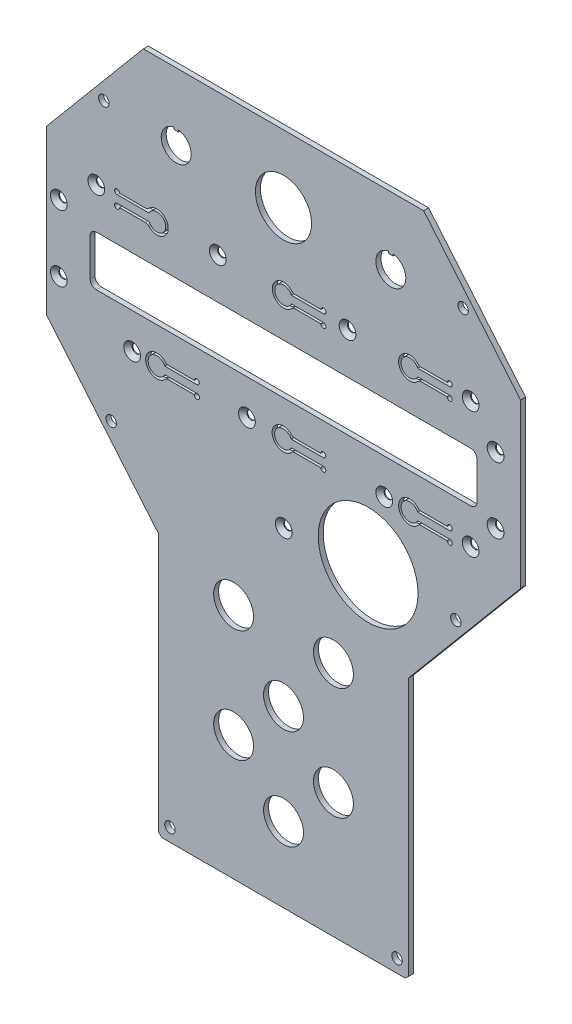
from build123d import *

# Parameters (mm, degrees)
RESSALTO_EXTRUS_O1_DEPTH                      = 2
CORTE_EXTRUS_O1_REACH                         = 4
ESBO_O2_R                                     = 2.1
CORTE_EXTRUS_O2_REACH                         = 4
CORTE_EXTRUS_O3_REACH                         = 4
ESBO_O4_R                                     = 20
CORTE_EXTRUS_O4_REACH                         = 4
ESBO_O5_R                                     = 8
ESBO_O5_R_2                                   = 11.25
ESCAREADO_PARA_PARAFUSO_ALLEN_SEXTAV_2_COUNT  = 2
ESCAREADO_PARA_PARAFUSO_ALLEN_SEXTAV_2_PITCH  = 26.5
ESCAREADO_PARA_PARAFUSO_ALLEN_SEXTAV_3_COUNT  = 2
ESCAREADO_PARA_PARAFUSO_ALLEN_SEXTAV_3_PITCH  = 47.918783057
ESCAREADO_PARA_PARAFUSO_ALLEN_SEXTAV_4_COUNT  = 2
ESCAREADO_PARA_PARAFUSO_ALLEN_SEXTAV_4_PITCH  = 84.354894452
ESCAREADO_PARA_PARAFUSO_ALLEN_SEXTAV_5_COUNT  = 2
ESCAREADO_PARA_PARAFUSO_ALLEN_SEXTAV_5_PITCH  = 135.769067452
ESCAREADO_PARA_PARAFUSO_ALLEN_SEXTAV_6_COUNT  = 2
ESCAREADO_PARA_PARAFUSO_ALLEN_SEXTAV_6_PITCH  = 176.995056428
ESCAREADO_PARA_PARAFUSO_ALLEN_SEXTAV_7_COUNT  = 2
ESCAREADO_PARA_PARAFUSO_ALLEN_SEXTAV_7_PITCH  = 175
ESCAREADO_PARA_PARAFUSO_ALLEN_SEXTAV_8_COUNT  = 2
ESCAREADO_PARA_PARAFUSO_ALLEN_SEXTAV_8_PITCH  = 116.384068539
ESCAREADO_PARA_PARAFUSO_ALLEN_SEXTAV_9_COUNT  = 2
ESCAREADO_PARA_PARAFUSO_ALLEN_SEXTAV_9_PITCH  = 64.945475466
ESCAREADO_PARA_PARAFUSO_ALLEN_SEXTAV_10_COUNT = 2
ESCAREADO_PARA_PARAFUSO_ALLEN_SEXTAV_10_PITCH = 113.39334618
CORTE_EXTRUS_O5_DEPTH                         = 10
FILETE1_R                                     = 2
ESCAREADO_PARA_PARAFUSO_ALLEN_SEXTAV_12_COUNT = 2
ESCAREADO_PARA_PARAFUSO_ALLEN_SEXTAV_12_PITCH = 150
ESCAREADO_PARA_PARAFUSO_ALLEN_SEXTAV_13_COUNT = 2
ESCAREADO_PARA_PARAFUSO_ALLEN_SEXTAV_13_PITCH = 158.297944738


with BuildPart() as part:
    # Esboço1 → Ressalto-extrusão1 (new body)
    with BuildSketch(Plane.XY):
        Polygon((55.321046002, 133.809611411), (-57.006999458, 133.809611411), (-95.842976728, 87.526695978), (-95.842976728, 22.140182404), (-50.842976728, -31.488729263), (-50.842976728, -135.082673958), (-49.522853837, -136.190388589), (47.836900381, -136.190388589), (49.157023272, -135.082673958), (49.157023272, -31.488729263), (94.157023272, 22.140182404), (94.157023272, 87.526695978), align=None)
    extrude(amount=RESSALTO_EXTRUS_O1_DEPTH)

    # Esboço2 → Corte-extrusão1 (cut, up to next)
    with BuildSketch(Plane.XY.offset(2), mode=Mode.PRIVATE) as corte_extrus_o1_sk1:
        with Locations((-72.814392548, 107.949888211)):
            Circle(ESBO_O2_R)
    corte_extrus_o1_tool1 = extrude(corte_extrus_o1_sk1.sketch, amount=-CORTE_EXTRUS_O1_REACH, mode=Mode.PRIVATE) & part.part
    add(corte_extrus_o1_tool1.solids().sort_by_distance((-72.814393, 107.949888, 2))[0], mode=Mode.SUBTRACT)
    # Esboço2 → Corte-extrusão1 (cut, up to next)
    with BuildSketch(Plane.XY.offset(2), mode=Mode.PRIVATE) as corte_extrus_o1_sk2:
        with Locations((-46.342976728, -130.964393909)):
            Circle(ESBO_O2_R)
    corte_extrus_o1_tool2 = extrude(corte_extrus_o1_sk2.sketch, amount=-CORTE_EXTRUS_O1_REACH, mode=Mode.PRIVATE) & part.part
    add(corte_extrus_o1_tool2.solids().sort_by_distance((-46.342977, -130.964394, 2))[0], mode=Mode.SUBTRACT)
    # Esboço2 → Corte-extrusão1 (cut, up to next)
    with BuildSketch(Plane.XY.offset(2), mode=Mode.PRIVATE) as corte_extrus_o1_sk3:
        with Locations((44.657023272, -130.964393909)):
            Circle(ESBO_O2_R)
    corte_extrus_o1_tool3 = extrude(corte_extrus_o1_sk3.sketch, amount=-CORTE_EXTRUS_O1_REACH, mode=Mode.PRIVATE) & part.part
    add(corte_extrus_o1_tool3.solids().sort_by_distance((44.657023, -130.964394, 2))[0], mode=Mode.SUBTRACT)
    # Esboço2 → Corte-extrusão1 (cut, up to next)
    with BuildSketch(Plane.XY.offset(2), mode=Mode.PRIVATE) as corte_extrus_o1_sk4:
        with Locations((71.128439092, 107.949888211)):
            Circle(ESBO_O2_R)
    corte_extrus_o1_tool4 = extrude(corte_extrus_o1_sk4.sketch, amount=-CORTE_EXTRUS_O1_REACH, mode=Mode.PRIVATE) & part.part
    add(corte_extrus_o1_tool4.solids().sort_by_distance((71.128439, 107.949888, 2))[0], mode=Mode.SUBTRACT)
    # Esboço2 → Corte-extrusão1 (cut, up to next)
    with BuildSketch(Plane.XY.offset(2), mode=Mode.PRIVATE) as corte_extrus_o1_sk5:
        with Locations((-69.895776734, -1.781729186)):
            Circle(ESBO_O2_R)
    corte_extrus_o1_tool5 = extrude(corte_extrus_o1_sk5.sketch, amount=-CORTE_EXTRUS_O1_REACH, mode=Mode.PRIVATE) & part.part
    add(corte_extrus_o1_tool5.solids().sort_by_distance((-69.895777, -1.781729, 2))[0], mode=Mode.SUBTRACT)
    # Esboço2 → Corte-extrusão1 (cut, up to next)
    with BuildSketch(Plane.XY.offset(2), mode=Mode.PRIVATE) as corte_extrus_o1_sk6:
        with Locations((68.209823278, -1.781729186)):
            Circle(ESBO_O2_R)
    corte_extrus_o1_tool6 = extrude(corte_extrus_o1_sk6.sketch, amount=-CORTE_EXTRUS_O1_REACH, mode=Mode.PRIVATE) & part.part
    add(corte_extrus_o1_tool6.solids().sort_by_distance((68.209823, -1.781729, 2))[0], mode=Mode.SUBTRACT)

    # Esboço3 → Corte-extrusão2 (cut, up to next)
    with BuildSketch(Plane.XY.offset(2), mode=Mode.PRIVATE) as corte_extrus_o2_sk1:
        with BuildLine():
            Line((-75.842976728, 40.809611411), (74.157023272, 40.809611411))
            ThreePointArc((74.157023272, 40.809611411), (75.924790225, 41.541844458), (76.657023272, 43.309611411))
            Line((76.657023272, 43.309611411), (76.657023272, 58.309611411))
            ThreePointArc((76.657023272, 58.309611411), (75.924790225, 60.077378364), (74.157023272, 60.809611411))
            Line((74.157023272, 60.809611411), (-75.842976728, 60.809611411))
            ThreePointArc((-75.842976728, 60.809611411), (-77.610743681, 60.077378364), (-78.342976728, 58.309611411))
            Line((-78.342976728, 58.309611411), (-78.342976728, 43.309611411))
            ThreePointArc((-78.342976728, 43.309611411), (-77.610743681, 41.541844458), (-75.842976728, 40.809611411))
        make_face()
    corte_extrus_o2_tool1 = extrude(corte_extrus_o2_sk1.sketch, amount=-CORTE_EXTRUS_O2_REACH, mode=Mode.PRIVATE) & part.part
    add(corte_extrus_o2_tool1.solids().sort_by_distance((-0.842977, 50.809611, 2))[0], mode=Mode.SUBTRACT)

    # Esboço4 → Corte-extrusão3 (cut, up to next)
    with BuildSketch(Plane.XY.offset(2), mode=Mode.PRIVATE) as corte_extrus_o3_sk1:
        with Locations((33.056325833, -0.190388589)):
            Circle(ESBO_O4_R)
    corte_extrus_o3_tool1 = extrude(corte_extrus_o3_sk1.sketch, amount=-CORTE_EXTRUS_O3_REACH, mode=Mode.PRIVATE) & part.part
    add(corte_extrus_o3_tool1.solids().sort_by_distance((33.056326, -0.190389, 2))[0], mode=Mode.SUBTRACT)

    # Esboço5 → Corte-extrusão4 (cut, up to next)
    with BuildSketch(Plane.XY.offset(2), mode=Mode.PRIVATE) as corte_extrus_o4_sk1:
        with Locations((-20.842976728, -86.190388589)):
            Circle(ESBO_O5_R)
    corte_extrus_o4_tool1 = extrude(corte_extrus_o4_sk1.sketch, amount=-CORTE_EXTRUS_O4_REACH, mode=Mode.PRIVATE) & part.part
    add(corte_extrus_o4_tool1.solids().sort_by_distance((-20.842977, -86.190389, 2))[0], mode=Mode.SUBTRACT)
    # Esboço5 → Corte-extrusão4 (cut, up to next)
    with BuildSketch(Plane.XY.offset(2), mode=Mode.PRIVATE) as corte_extrus_o4_sk2:
        with Locations((19.157023272, -86.190388589)):
            Circle(ESBO_O5_R)
    corte_extrus_o4_tool2 = extrude(corte_extrus_o4_sk2.sketch, amount=-CORTE_EXTRUS_O4_REACH, mode=Mode.PRIVATE) & part.part
    add(corte_extrus_o4_tool2.solids().sort_by_distance((19.157023, -86.190389, 2))[0], mode=Mode.SUBTRACT)
    # Esboço5 → Corte-extrusão4 (cut, up to next)
    with BuildSketch(Plane.XY.offset(2), mode=Mode.PRIVATE) as corte_extrus_o4_sk3:
        with Locations((-0.842976728, -106.190388589)):
            Circle(ESBO_O5_R)
    corte_extrus_o4_tool3 = extrude(corte_extrus_o4_sk3.sketch, amount=-CORTE_EXTRUS_O4_REACH, mode=Mode.PRIVATE) & part.part
    add(corte_extrus_o4_tool3.solids().sort_by_distance((-0.842977, -106.190389, 2))[0], mode=Mode.SUBTRACT)
    # Esboço5 → Corte-extrusão4 (cut, up to next)
    with BuildSketch(Plane.XY.offset(2), mode=Mode.PRIVATE) as corte_extrus_o4_sk4:
        with Locations((-0.842976728, -66.190388589)):
            Circle(ESBO_O5_R)
    corte_extrus_o4_tool4 = extrude(corte_extrus_o4_sk4.sketch, amount=-CORTE_EXTRUS_O4_REACH, mode=Mode.PRIVATE) & part.part
    add(corte_extrus_o4_tool4.solids().sort_by_distance((-0.842977, -66.190389, 2))[0], mode=Mode.SUBTRACT)
    # Esboço5 → Corte-extrusão4 (cut, up to next)
    with BuildSketch(Plane.XY.offset(2), mode=Mode.PRIVATE) as corte_extrus_o4_sk5:
        with Locations((-20.842976728, -41.190388589)):
            Circle(ESBO_O5_R)
    corte_extrus_o4_tool5 = extrude(corte_extrus_o4_sk5.sketch, amount=-CORTE_EXTRUS_O4_REACH, mode=Mode.PRIVATE) & part.part
    add(corte_extrus_o4_tool5.solids().sort_by_distance((-20.842977, -41.190389, 2))[0], mode=Mode.SUBTRACT)
    # Esboço5 → Corte-extrusão4 (cut, up to next)
    with BuildSketch(Plane.XY.offset(2), mode=Mode.PRIVATE) as corte_extrus_o4_sk6:
        with Locations((19.157023272, -41.190388589)):
            Circle(ESBO_O5_R)
    corte_extrus_o4_tool6 = extrude(corte_extrus_o4_sk6.sketch, amount=-CORTE_EXTRUS_O4_REACH, mode=Mode.PRIVATE) & part.part
    add(corte_extrus_o4_tool6.solids().sort_by_distance((19.157023, -41.190389, 2))[0], mode=Mode.SUBTRACT)
    # Esboço5 → Corte-extrusão4 (cut, up to next)
    with BuildSketch(Plane.XY.offset(2), mode=Mode.PRIVATE) as corte_extrus_o4_sk7:
        with Locations((-0.842976728, 106.809611411)):
            Circle(ESBO_O5_R_2)
    corte_extrus_o4_tool7 = extrude(corte_extrus_o4_sk7.sketch, amount=-CORTE_EXTRUS_O4_REACH, mode=Mode.PRIVATE) & part.part
    add(corte_extrus_o4_tool7.solids().sort_by_distance((-0.842977, 106.809611, 2))[0], mode=Mode.SUBTRACT)
    # Esboço5 → Corte-extrusão4 (cut, up to next)
    with BuildSketch(Plane.XY.offset(2), mode=Mode.PRIVATE) as corte_extrus_o4_sk8:
        with BuildLine():
            Line((-44.742976728, 112.741727391), (-44.742976728, 111.941727391))
            Line((-44.742976728, 111.941727391), (-42.942976728, 111.941727391))
            Line((-42.942976728, 111.941727391), (-42.942976728, 112.741727391))
            ThreePointArc((-42.942976728, 112.741727391), (-43.842976728, 100.809611411), (-44.742976728, 112.741727391))
        make_face()
    corte_extrus_o4_tool8 = extrude(corte_extrus_o4_sk8.sketch, amount=-CORTE_EXTRUS_O4_REACH, mode=Mode.PRIVATE) & part.part
    add(corte_extrus_o4_tool8.solids().sort_by_distance((-43.842977, 106.733858, 2))[0], mode=Mode.SUBTRACT)
    # Esboço5 → Corte-extrusão4 (cut, up to next)
    with BuildSketch(Plane.XY.offset(2), mode=Mode.PRIVATE) as corte_extrus_o4_sk9:
        with BuildLine():
            Line((41.257023272, 112.741727391), (41.257023272, 111.941727391))
            Line((41.257023272, 111.941727391), (43.057023272, 111.941727391))
            Line((43.057023272, 111.941727391), (43.057023272, 112.741727391))
            ThreePointArc((43.057023272, 112.741727391), (42.157023272, 100.809611411), (41.257023272, 112.741727391))
        make_face()
    corte_extrus_o4_tool9 = extrude(corte_extrus_o4_sk9.sketch, amount=-CORTE_EXTRUS_O4_REACH, mode=Mode.PRIVATE) & part.part
    add(corte_extrus_o4_tool9.solids().sort_by_distance((42.157023, 106.733858, 2))[0], mode=Mode.SUBTRACT)

    # Esboço11 → Escareado para parafuso Allen sextavado (revolve, cut)
    with BuildSketch(Plane(origin=(-90.868976728, 64.471011411, 2), x_dir=(0, -1, 0), z_dir=(1, 0, 0))):
        Polygon((0, 0), (0, 2), (1.7, 2), (1.7, 1.66), (3.36, 0), align=None)
    escareado_para_parafuso_allen_sextavado = revolve(axis=Axis((-90.868976728, 64.471011411, 8.35), (0, 0, -1)), mode=Mode.SUBTRACT)

    # Escareado para parafuso Allen sextav 2: Escareado para parafuso Allen sextavado ×2
    with Locations(*[(0, -i * ESCAREADO_PARA_PARAFUSO_ALLEN_SEXTAV_2_PITCH, 0) for i in range(1, ESCAREADO_PARA_PARAFUSO_ALLEN_SEXTAV_2_COUNT)]):
        add(escareado_para_parafuso_allen_sextavado, mode=Mode.SUBTRACT)

    # Escareado para parafuso Allen sextav 3: Escareado para parafuso Allen sextavado ×2
    with Locations(*[Vector(0.613251976, -0.789887343, 0) * (i * ESCAREADO_PARA_PARAFUSO_ALLEN_SEXTAV_3_PITCH) for i in range(1, ESCAREADO_PARA_PARAFUSO_ALLEN_SEXTAV_3_COUNT)]):
        add(escareado_para_parafuso_allen_sextavado, mode=Mode.SUBTRACT)

    # Escareado para parafuso Allen sextav 4: Escareado para parafuso Allen sextavado ×2
    with Locations(*[Vector(0.893680068, -0.448704731, 0) * (i * ESCAREADO_PARA_PARAFUSO_ALLEN_SEXTAV_4_PITCH) for i in range(1, ESCAREADO_PARA_PARAFUSO_ALLEN_SEXTAV_4_COUNT)]):
        add(escareado_para_parafuso_allen_sextavado, mode=Mode.SUBTRACT)

    # Escareado para parafuso Allen sextav 5: Escareado para parafuso Allen sextavado ×2
    with Locations(*[Vector(0.960353411, -0.278785447, 0) * (i * ESCAREADO_PARA_PARAFUSO_ALLEN_SEXTAV_5_PITCH) for i in range(1, ESCAREADO_PARA_PARAFUSO_ALLEN_SEXTAV_5_COUNT)]):
        add(escareado_para_parafuso_allen_sextavado, mode=Mode.SUBTRACT)

    # Escareado para parafuso Allen sextav 6: Escareado para parafuso Allen sextavado ×2
    with Locations(*[Vector(0.98872818, -0.149721696, 0) * (i * ESCAREADO_PARA_PARAFUSO_ALLEN_SEXTAV_6_PITCH) for i in range(1, ESCAREADO_PARA_PARAFUSO_ALLEN_SEXTAV_6_COUNT)]):
        add(escareado_para_parafuso_allen_sextavado, mode=Mode.SUBTRACT)

    # Escareado para parafuso Allen sextav 7: Escareado para parafuso Allen sextavado ×2
    with Locations(*[(i * ESCAREADO_PARA_PARAFUSO_ALLEN_SEXTAV_7_PITCH, 0, 0) for i in range(1, ESCAREADO_PARA_PARAFUSO_ALLEN_SEXTAV_7_COUNT)]):
        add(escareado_para_parafuso_allen_sextavado, mode=Mode.SUBTRACT)

    # Escareado para parafuso Allen sextav 8: Escareado para parafuso Allen sextavado ×2
    with Locations(*[Vector(0.994001416, 0.109367203, 0) * (i * ESCAREADO_PARA_PARAFUSO_ALLEN_SEXTAV_8_PITCH) for i in range(1, ESCAREADO_PARA_PARAFUSO_ALLEN_SEXTAV_8_COUNT)]):
        add(escareado_para_parafuso_allen_sextavado, mode=Mode.SUBTRACT)

    # Escareado para parafuso Allen sextav 9: Escareado para parafuso Allen sextavado ×2
    with Locations(*[Vector(0.98060609, 0.195989019, 0) * (i * ESCAREADO_PARA_PARAFUSO_ALLEN_SEXTAV_9_PITCH) for i in range(1, ESCAREADO_PARA_PARAFUSO_ALLEN_SEXTAV_9_COUNT)]):
        add(escareado_para_parafuso_allen_sextavado, mode=Mode.SUBTRACT)

    # Escareado para parafuso Allen sextav 10: Escareado para parafuso Allen sextavado ×2
    with Locations(*[Vector(0.794899268, -0.606741423, 0) * (i * ESCAREADO_PARA_PARAFUSO_ALLEN_SEXTAV_10_PITCH) for i in range(1, ESCAREADO_PARA_PARAFUSO_ALLEN_SEXTAV_10_COUNT)]):
        add(escareado_para_parafuso_allen_sextavado, mode=Mode.SUBTRACT)

    # Esboço12 → Corte-extrusão5 (cut)
    with BuildSketch(Plane.XY.offset(2)):
        with BuildLine():
            Line((52.929300932, 28.019611411), (65.767023272, 28.019611411))
            ThreePointArc((65.767023272, 28.019611411), (66.474130053, 29.726718193), (64.767023272, 29.019611411))
            Line((64.767023272, 29.019611411), (53.508680659, 29.019611411))
            ThreePointArc((53.508680659, 29.019611411), (45.267023272, 26.519611411), (53.508680659, 24.019611411))
            Line((53.508680659, 24.019611411), (64.767023272, 24.019611411))
            ThreePointArc((64.767023272, 24.019611411), (66.474130053, 23.31250463), (65.767023272, 25.019611411))
            Line((65.767023272, 25.019611411), (52.929300932, 25.019611411))
            ThreePointArc((52.929300932, 25.019611411), (46.267023272, 26.519611411), (52.929300932, 28.019611411))
        make_face()
        with BuildLine():
            Line((2.259300932, 28.019611411), (15.097023272, 28.019611411))
            ThreePointArc((15.097023272, 28.019611411), (15.804130053, 29.726718193), (14.097023272, 29.019611411))
            Line((14.097023272, 29.019611411), (2.838680659, 29.019611411))
            ThreePointArc((2.838680659, 29.019611411), (-5.402976728, 26.519611411), (2.838680659, 24.019611411))
            Line((2.838680659, 24.019611411), (14.097023272, 24.019611411))
            ThreePointArc((14.097023272, 24.019611411), (15.804130053, 23.31250463), (15.097023272, 25.019611411))
            Line((15.097023272, 25.019611411), (2.259300932, 25.019611411))
            ThreePointArc((2.259300932, 25.019611411), (-4.402976728, 26.519611411), (2.259300932, 28.019611411))
        make_face()
        with BuildLine():
            Line((-48.410699068, 28.019611411), (-35.572976728, 28.019611411))
            ThreePointArc((-35.572976728, 28.019611411), (-34.865869947, 29.726718193), (-36.572976728, 29.019611411))
            Line((-36.572976728, 29.019611411), (-47.831319341, 29.019611411))
            ThreePointArc((-47.831319341, 29.019611411), (-56.072976728, 26.519611411), (-47.831319341, 24.019611411))
            Line((-47.831319341, 24.019611411), (-36.653425887, 24.019611411))
            ThreePointArc((-36.653425887, 24.019611411), (-34.675928196, 23.417386939), (-35.982085986, 25.019611411))
            Line((-35.982085986, 25.019611411), (-48.410699068, 25.019611411))
            ThreePointArc((-48.410699068, 25.019611411), (-55.072976728, 26.519611411), (-48.410699068, 28.019611411))
        make_face()
        with BuildLine():
            Line((2.329300932, 77.979611411), (15.167023272, 77.979611411))
            ThreePointArc((15.167023272, 77.979611411), (15.874130053, 79.686718193), (14.167023272, 78.979611411))
            Line((14.167023272, 78.979611411), (2.908680659, 78.979611411))
            ThreePointArc((2.908680659, 78.979611411), (-5.332976728, 76.479611411), (2.908680659, 73.979611411))
            Line((2.908680659, 73.979611411), (14.167023272, 73.979611411))
            ThreePointArc((14.167023272, 73.979611411), (15.874130053, 73.27250463), (15.167023272, 74.979611411))
            Line((15.167023272, 74.979611411), (2.329300932, 74.979611411))
            ThreePointArc((2.329300932, 74.979611411), (-4.332976728, 76.479611411), (2.329300932, 77.979611411))
        make_face()
        with BuildLine():
            Line((52.929300932, 77.979611411), (65.767023272, 77.979611411))
            ThreePointArc((65.767023272, 77.979611411), (66.474130053, 79.686718193), (64.767023272, 78.979611411))
            Line((64.767023272, 78.979611411), (53.508680659, 78.979611411))
            ThreePointArc((53.508680659, 78.979611411), (45.267023272, 76.479611411), (53.508680659, 73.979611411))
            Line((53.508680659, 73.979611411), (64.767023272, 73.979611411))
            ThreePointArc((64.767023272, 73.979611411), (66.474130053, 73.27250463), (65.767023272, 74.979611411))
            Line((65.767023272, 74.979611411), (52.929300932, 74.979611411))
            ThreePointArc((52.929300932, 74.979611411), (46.267023272, 76.479611411), (52.929300932, 77.979611411))
        make_face()
        with BuildLine():
            Line((-54.695254388, 77.979611411), (-67.532976728, 77.979611411))
            ThreePointArc((-67.532976728, 77.979611411), (-68.240083509, 79.686718193), (-66.532976728, 78.979611411))
            Line((-66.532976728, 78.979611411), (-55.274634115, 78.979611411))
            ThreePointArc((-55.274634115, 78.979611411), (-47.032976728, 76.479611411), (-55.274634115, 73.979611411))
            Line((-55.274634115, 73.979611411), (-66.532976728, 73.979611411))
            ThreePointArc((-66.532976728, 73.979611411), (-68.240083509, 73.27250463), (-67.532976728, 74.979611411))
            Line((-67.532976728, 74.979611411), (-54.695254388, 74.979611411))
            ThreePointArc((-54.695254388, 74.979611411), (-48.032976728, 76.479611411), (-54.695254388, 77.979611411))
        make_face()
    extrude(amount=-CORTE_EXTRUS_O5_DEPTH, mode=Mode.SUBTRACT)

    # Filete1
    filete1_edges = [part.edges().sort_by_distance(p)[0] for p in [
        (53.508680659, 29.019611411, 1),
        (-47.831319341, 24.019611411, 1),
        (-47.831319341, 29.019611411, 1),
        (-55.274634115, 78.979611411, 1),
        (-55.274634115, 73.979611411, 1),
        (2.908680659, 73.979611411, 1),
        (2.908680659, 78.979611411, 1),
        (53.508680659, 73.979611411, 1),
        (53.508680659, 78.979611411, 1),
        (2.838680659, 24.019611411, 1),
        (2.838680659, 29.019611411, 1),
    ]]
    fillet(filete1_edges, radius=FILETE1_R)

    # Esboço14 → Escareado para parafuso Allen sextav 11 (revolve, cut)
    with BuildSketch(Plane(origin=(-75.842976728, 77.199611411, 2), x_dir=(0, -1, 0), z_dir=(1, 0, 0))):
        Polygon((0, 0), (0, 2), (1.7, 2), (1.7, 1.66), (3.36, 0), align=None)
    escareado_para_parafuso_allen_sextav_11 = revolve(axis=Axis((-75.842976728, 77.199611411, 8.35), (0, 0, -1)), mode=Mode.SUBTRACT)

    # Escareado para parafuso Allen sextav 12: Escareado para parafuso Allen sextav 11 ×2
    with Locations(*[(i * ESCAREADO_PARA_PARAFUSO_ALLEN_SEXTAV_12_PITCH, 0, 0) for i in range(1, ESCAREADO_PARA_PARAFUSO_ALLEN_SEXTAV_12_COUNT)]):
        add(escareado_para_parafuso_allen_sextav_11, mode=Mode.SUBTRACT)

    # Escareado para parafuso Allen sextav 13: Escareado para parafuso Allen sextav 11 ×2
    with Locations(*[Vector(0.947580212, -0.319517984, 0) * (i * ESCAREADO_PARA_PARAFUSO_ALLEN_SEXTAV_13_PITCH) for i in range(1, ESCAREADO_PARA_PARAFUSO_ALLEN_SEXTAV_13_COUNT)]):
        add(escareado_para_parafuso_allen_sextav_11, mode=Mode.SUBTRACT)


solid = part.part
